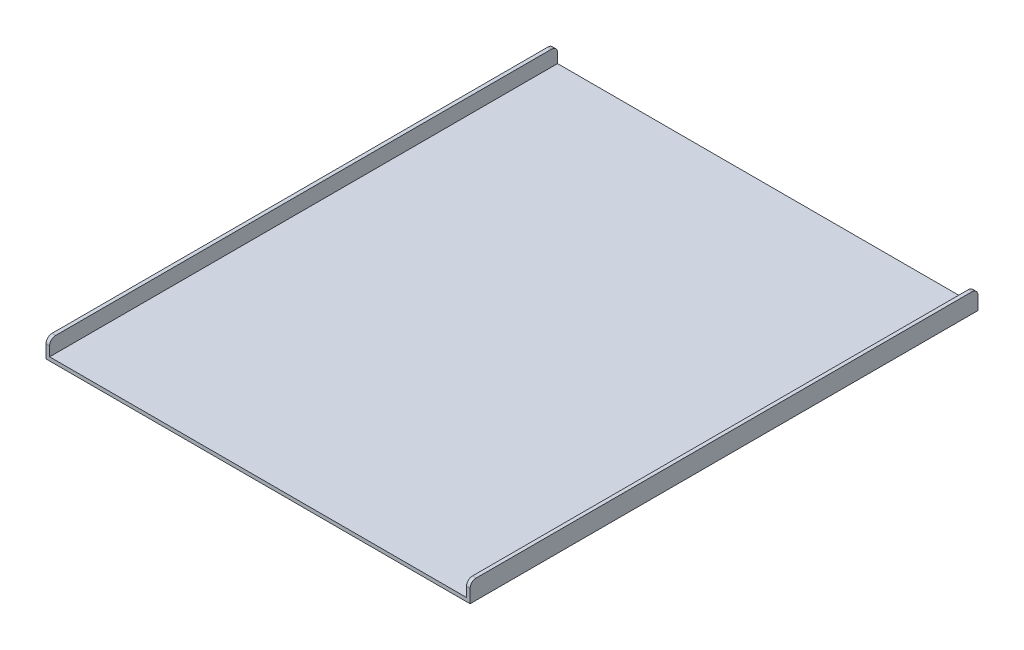
from build123d import *

# Parameters (mm, degrees)
EXTRUDE_THIN1_DEPTH = 421.049210887
FILLET1_R           = 10
SKETCH_2_R          = 19.05
EXTRUDE_1_DEPTH     = 23.24974156
SKETCH_3_R          = 19.05
EXTRUDE_2_DEPTH     = 26


with BuildPart() as part:
    # Sketch1 → Extrude-Thin1 (new body, symmetric)
    with BuildSketch(Plane.XY):
        Polygon((-250.514148937, 25.753634758), (-250.514148937, 0), (440.503291061, 0), (440.503291061, 25.915671281), (446.551474959, 25.915671281), (446.551474959, -6.048183898), (-256.562332835, -6.048183898), (-256.562332835, 25.753634758), align=None)
    extrude(amount=EXTRUDE_THIN1_DEPTH, both=True)

    # Fillet1
    fillet1_edges = [part.edges().sort_by_distance(p)[0] for p in [
        (-253.538240886, 25.753634758, 421.049210887),
        (443.52738301, 25.915671281, 421.049210887),
        (-253.538240886, 25.753634758, -421.049210887),
        (443.52738301, 25.915671281, -421.049210887),
    ]]
    fillet(fillet1_edges, radius=FILLET1_R)

    # 草图2 → 凸台-拉伸1 (add)
    with BuildSketch(Plane(origin=(0, -6.048183898, 0), x_dir=(-1, 0, 0), z_dir=(0, -1, 0))):
        with Locations((-360.164689426, 358.012657815)):
            Circle(SKETCH_2_R)
    extrude(amount=EXTRUDE_1_DEPTH)

    # 草图3 → 凸台-拉伸2 (add)
    with BuildSketch(Plane(origin=(0, -6.048183898, 0), x_dir=(-1, 0, 0), z_dir=(0, -1, 0))):
        with Locations((175.410326922, -359.721177401)):
            Circle(SKETCH_3_R)
    extrude(amount=EXTRUDE_2_DEPTH)


solid = part.part
